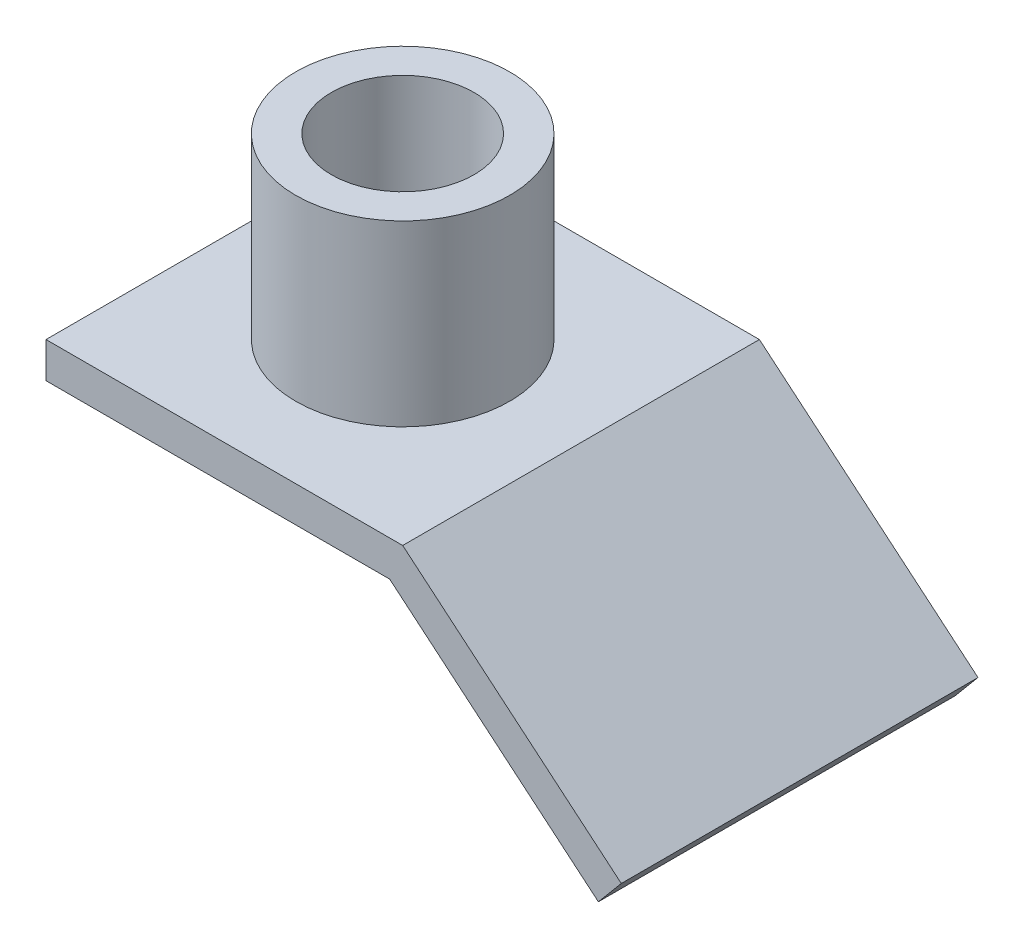
from build123d import *

# Parameters (mm, degrees)
EXTRUDE_THIN1_DEPTH = 50
SKETCH3_R           = 30
BOSS_EXTRUDE1_DEPTH = 50
SKETCH4_R           = 20
CUT_EXTRUDE1_DEPTH  = 110.083453206


with BuildPart() as part:
    # Sketch1 → Extrude-Thin1 (new body, symmetric)
    with BuildSketch(Plane.XY):
        Polygon((-50, 0), (50, 0), (111.28355545, -51.423008775), (104.855679353, -59.083453206), (46.360297657, -10), (-50, -10), align=None)
    extrude(amount=EXTRUDE_THIN1_DEPTH, both=True)

    # Sketch3 → Boss-Extrude1 (add)
    with BuildSketch(Plane(origin=(0, 0, 0), x_dir=(1, 0, 0), z_dir=(0, 1, 0))):
        Circle(SKETCH3_R)
    extrude(amount=BOSS_EXTRUDE1_DEPTH)

    # Sketch4 → Cut-Extrude1 (cut, through all)
    with BuildSketch(Plane(origin=(0, 50, 0), x_dir=(1, 0, 0), z_dir=(0, 1, 0))):
        Circle(SKETCH4_R)
    extrude(amount=-CUT_EXTRUDE1_DEPTH, mode=Mode.SUBTRACT)


solid = part.part
